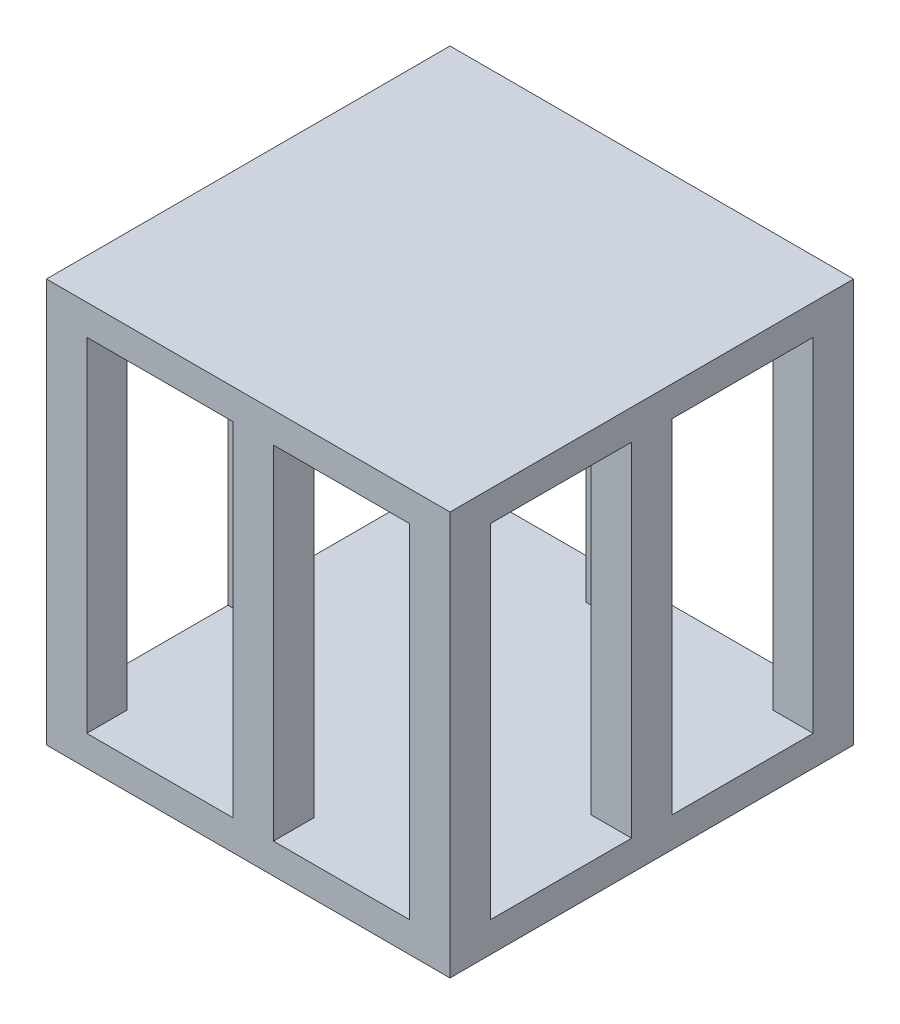
from build123d import *

# Parameters (mm, degrees)
SKETCH1_W           = 5.08
SKETCH1_H           = 5.08
BOSS_EXTRUDE1_DEPTH = 21.59
LPATTERN2_COUNT     = 3
LPATTERN2_PITCH     = 22.86
LPATTERN3_COUNT     = 2
LPATTERN3_PITCH     = 23.495
LPATTERN4_COUNT     = 2
LPATTERN4_PITCH     = 23.495
SKETCH2_W           = 50.8
SKETCH2_H           = 50.8
BOSS_EXTRUDE3_DEPTH = 3.81
SKETCH3_W           = 50.8
SKETCH3_H           = 50.8
BOSS_EXTRUDE4_DEPTH = 3.81


with BuildPart() as part:
    # Sketch1 → Boss-Extrude1 (new body, symmetric)
    with BuildSketch(Plane(origin=(0, 0, 0), x_dir=(1, 0, 0), z_dir=(0, 1, 0))):
        with Locations((-22.86, -22.86)):
            Rectangle(SKETCH1_W, SKETCH1_H)
    extrude(amount=BOSS_EXTRUDE1_DEPTH, both=True)


with BuildPart() as lpattern2_1:
    # LPattern2: pattern copy
    add(part.part.moved(Location(Vector(0, 0, -1) * (1 * LPATTERN2_PITCH))))


with BuildPart() as lpattern2_2:
    # LPattern2: pattern copy
    add(part.part.moved(Location(Vector(0, 0, -1) * (2 * LPATTERN2_PITCH))))


with BuildPart() as body_4:
    # Mirror1: mirrored copy
    add(lpattern2_2.part.mirror(Plane(origin=(0, 0, 0), x_dir=(0, 0, 1), z_dir=(1, 0, 0))))


with BuildPart() as body_5:
    # Mirror1 2: mirrored copy
    add(lpattern2_1.part.mirror(Plane(origin=(0, 0, 0), x_dir=(0, 0, 1), z_dir=(1, 0, 0))))


with BuildPart() as body_6:
    # Mirror1 3: mirrored copy
    add(part.part.mirror(Plane(origin=(0, 0, 0), x_dir=(0, 0, 1), z_dir=(1, 0, 0))))


with BuildPart() as lpattern3_1:
    # LPattern3: pattern copy
    add(part.part.moved(Location(Vector(1, 0, 0) * (1 * LPATTERN3_PITCH))))


with BuildPart() as lpattern4_1:
    # LPattern4: pattern copy
    add(body_4.part.moved(Location(Vector(-1, 0, 0) * (1 * LPATTERN4_PITCH))))


with BuildPart() as part_1:
    add(part.part)

    add(lpattern2_1.part)  # Boss-Extrude3 merges LPattern2_1

    add(lpattern2_2.part)  # Boss-Extrude3 merges LPattern2_2

    add(body_4.part)  # Boss-Extrude3 merges body 4

    add(body_5.part)  # Boss-Extrude3 merges body 5

    add(body_6.part)  # Boss-Extrude3 merges body 6

    add(lpattern3_1.part)  # Boss-Extrude3 merges LPattern3_1

    add(lpattern4_1.part)  # Boss-Extrude3 merges LPattern4_1
    # Sketch2 → Boss-Extrude3 (add)
    with BuildSketch(Plane(origin=(0, 21.59, 0), x_dir=(1, 0, 0), z_dir=(0, 1, 0))):
        Rectangle(SKETCH2_W, SKETCH2_H)
    extrude(amount=BOSS_EXTRUDE3_DEPTH)

    # Sketch3 → Boss-Extrude4 (add)
    with BuildSketch(Plane.XZ.offset(21.59)):
        Rectangle(SKETCH3_W, SKETCH3_H)
    extrude(amount=BOSS_EXTRUDE4_DEPTH)


solid = part_1.part
